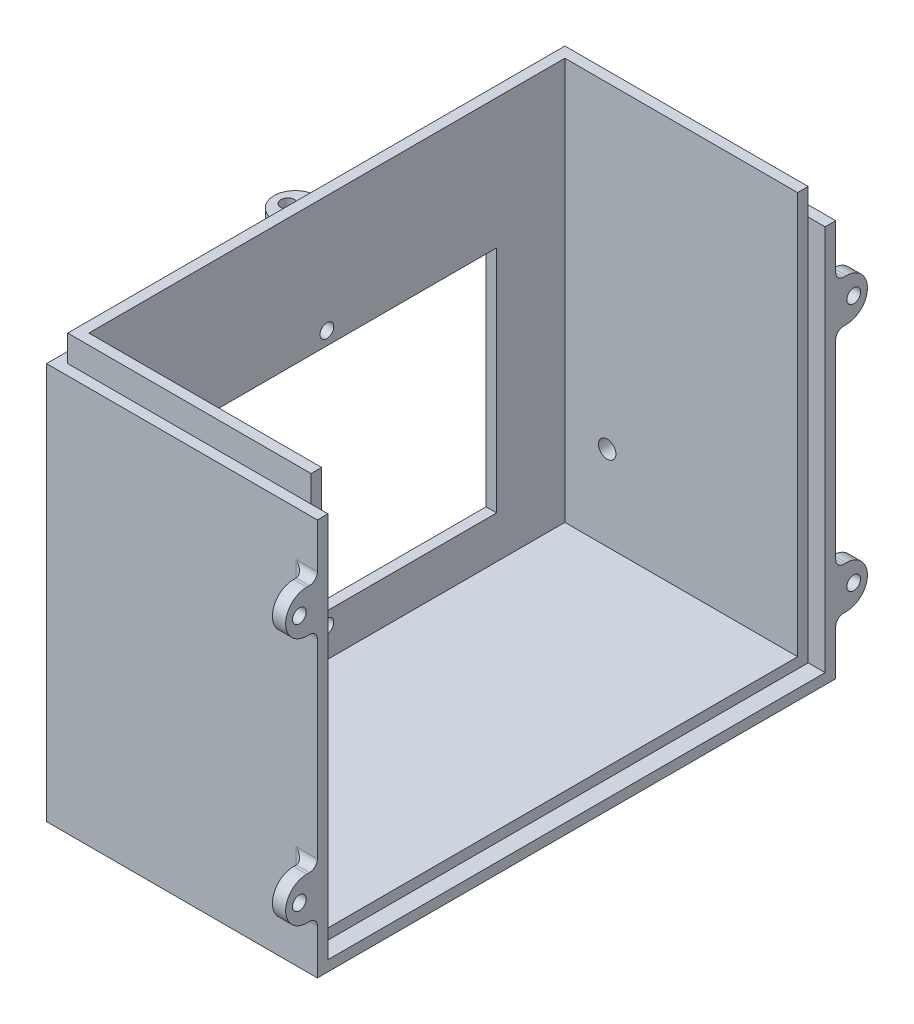
from build123d import *

# Parameters (mm, degrees)
SKETCH1_W           = 53
SKETCH1_H           = 98
BOSS_EXTRUDE1_DEPTH = 80
SKETCH2_W           = 90
SKETCH2_H           = 76
CUT_EXTRUDE1_DEPTH  = 49
SKETCH3_W           = 51
SKETCH3_H           = 2
CUT_EXTRUDE2_DEPTH  = 5
SKETCH5_W           = 2
SKETCH5_H           = 76
CUT_EXTRUDE3_DEPTH  = 5
CUT_EXTRUDE4_DEPTH  = 1.8
SKETCH8_R           = 1.3
BOSS_EXTRUDE3_DEPTH = 2.5
FILLET2_R           = 1.5
SKETCH9_R           = 1.3
BOSS_EXTRUDE4_DEPTH = 2.5
FILLET4_R           = 1.5
CUT_EXTRUDE6_REACH  = 53.2
SKETCH14_W          = 64.2
SKETCH14_H          = 43.4
SKETCH15_W          = 74.2
SKETCH15_H          = 53.4
CUT_EXTRUDE7_DEPTH  = 2
CUT_EXTRUDE8_REACH  = 51.2
SKETCH16_R          = 1.3
CUT_EXTRUDE12_REACH = 106
SKETCH29_R          = 1.65


with BuildPart() as part:
    # Sketch1 → Boss-Extrude1 (new body)
    with BuildSketch(Plane(origin=(0, 0, 0), x_dir=(1, 0, 0), z_dir=(0, 1, 0))):
        Rectangle(SKETCH1_W, SKETCH1_H)
    extrude(amount=BOSS_EXTRUDE1_DEPTH)

    # Sketch2 → Cut-Extrude1 (cut)
    with BuildSketch(Plane(origin=(26.5, 0, 0), x_dir=(0, 0, -1), z_dir=(1, 0, 0))):
        with Locations((0, 42)):
            Rectangle(SKETCH2_W, SKETCH2_H)
    extrude(amount=-CUT_EXTRUDE1_DEPTH, mode=Mode.SUBTRACT)

    # Sketch3 → Cut-Extrude2 (cut)
    with BuildSketch(Plane(origin=(0, 80, 0), x_dir=(1, 0, 0), z_dir=(0, 1, 0))):
        Polygon((-26.5, -49), (26.5, -49), (26.5, -47), (-24.5, -47), (-26.5, -47), align=None)
        Polygon((-26.5, 49), (-26.5, -47), (-24.5, -47), (-24.5, 47), (-24.5, 49), align=None)
        with Locations((1, 48)):
            Rectangle(SKETCH3_W, SKETCH3_H)
    extrude(amount=-CUT_EXTRUDE2_DEPTH, mode=Mode.SUBTRACT)

    # Sketch5 → Cut-Extrude3 (cut)
    with BuildSketch(Plane(origin=(26.5, 0, 0), x_dir=(0, 0, -1), z_dir=(1, 0, 0))):
        with Locations((-46, 42)):
            Rectangle(SKETCH5_W, SKETCH5_H)
        Polygon((-45, 4), (-47, 4), (-47, 2), (47, 2), (47, 4), (45, 4), align=None)
        with Locations((46, 42)):
            Rectangle(SKETCH5_W, SKETCH5_H)
    extrude(amount=-CUT_EXTRUDE3_DEPTH, mode=Mode.SUBTRACT)

    # Sketch6 → Cut-Extrude4 (cut)
    with BuildSketch(Plane(origin=(26.5, 0, 0), x_dir=(0, 0, -1), z_dir=(1, 0, 0))):
        Polygon((47, 75), (47, 2), (-47, 2), (-47, 75), (-49, 75), (-49, 0), (49, 0), (49, 75), align=None)
    extrude(amount=-CUT_EXTRUDE4_DEPTH, mode=Mode.SUBTRACT)

    # Sketch8 → Boss-Extrude3 (add)
    with BuildSketch(Plane(origin=(24.7, 0, 0), x_dir=(0, 0, -1), z_dir=(1, 0, 0))):
        with BuildLine():
            Line((-49, 10), (-51, 10))
            ThreePointArc((-51, 10), (-55, 14), (-51, 18))
            Line((-51, 18), (-49, 18))
            Line((-49, 18), (-49, 10))
        make_face()
        with Locations((-52.4, 14)):
            Circle(SKETCH8_R, mode=Mode.SUBTRACT)
        with BuildLine():
            Line((-49, 65), (-49, 57))
            Line((-49, 57), (-51, 57))
            ThreePointArc((-51, 57), (-55, 61), (-51, 65))
            Line((-51, 65), (-49, 65))
        make_face()
        with Locations((-52.4, 61)):
            Circle(SKETCH8_R, mode=Mode.SUBTRACT)
        with BuildLine():
            Line((49, 10), (49, 18))
            Line((49, 18), (51, 18))
            ThreePointArc((51, 18), (55, 14), (51, 10))
            Line((51, 10), (49, 10))
        make_face()
        with Locations((52.4, 14)):
            Circle(SKETCH8_R, mode=Mode.SUBTRACT)
        with BuildLine():
            Line((49, 65), (51, 65))
            ThreePointArc((51, 65), (55, 61), (51, 57))
            Line((51, 57), (49, 57))
            Line((49, 57), (49, 65))
        make_face()
        with Locations((52.4, 61)):
            Circle(SKETCH8_R, mode=Mode.SUBTRACT)
    extrude(amount=-BOSS_EXTRUDE3_DEPTH)

    # Fillet2
    fillet2_edges = [part.edges().sort_by_distance(p)[0] for p in [
        (22.2, 14, 49),
        (23.45, 18, 49),
        (23.45, 10, 49),
        (22.2, 61, 49),
        (23.45, 65, 49),
        (23.45, 57, 49),
        (22.2, 14, -49),
        (23.45, 10, -49),
        (23.45, 18, -49),
        (22.2, 61, -49),
        (23.45, 57, -49),
        (23.45, 65, -49),
    ]]
    fillet(fillet2_edges, radius=FILLET2_R)

    # Sketch9 → Boss-Extrude4 (add)
    with BuildSketch(Plane(origin=(0, 75, 0), x_dir=(1, 0, 0), z_dir=(0, 1, 0))):
        with BuildLine():
            Line((-26.5, 4), (-28.5, 4))
            ThreePointArc((-28.5, 4), (-32.5, 0), (-28.5, -4))
            Line((-28.5, -4), (-26.5, -4))
            Line((-26.5, -4), (-26.5, 4))
        make_face()
        with Locations((-29.9, 0)):
            Circle(SKETCH9_R, mode=Mode.SUBTRACT)
    extrude(amount=-BOSS_EXTRUDE4_DEPTH)

    # Fillet4
    fillet4_edges = [part.edges().sort_by_distance(p)[0] for p in [
        (-26.5, 72.5, 0),
        (-26.5, 73.75, -4),
        (-26.5, 73.75, 4),
    ]]
    fillet(fillet4_edges, radius=FILLET4_R)

    # Sketch14 → Cut-Extrude6 (cut, up to next)
    with BuildSketch(Plane.ZY.offset(26.5), mode=Mode.PRIVATE) as cut_extrude6_sk1:
        with Locations((0, 33.7)):
            Rectangle(SKETCH14_W, SKETCH14_H)
    cut_extrude6_tool1 = extrude(cut_extrude6_sk1.sketch, amount=-CUT_EXTRUDE6_REACH, mode=Mode.PRIVATE) & part.part
    add(cut_extrude6_tool1.solids().sort_by_distance((-26.5, 33.7, 0))[0], mode=Mode.SUBTRACT)

    # Sketch15 → Cut-Extrude7 (cut)
    with BuildSketch(Plane.ZY.offset(26.5)):
        with Locations((0, 33.7)):
            Rectangle(SKETCH15_W, SKETCH15_H)
    extrude(amount=-CUT_EXTRUDE7_DEPTH, mode=Mode.SUBTRACT)

    # Sketch16 → Cut-Extrude8 (cut, up to next)
    with BuildSketch(Plane.ZY.offset(24.5), mode=Mode.PRIVATE) as cut_extrude8_sk1:
        with Locations((0, 57.9)):
            Circle(SKETCH16_R)
    cut_extrude8_tool1 = extrude(cut_extrude8_sk1.sketch, amount=-CUT_EXTRUDE8_REACH, mode=Mode.PRIVATE) & part.part
    add(cut_extrude8_tool1.solids().sort_by_distance((-24.5, 57.9, 0))[0], mode=Mode.SUBTRACT)
    # Sketch16 → Cut-Extrude8 (cut, up to next)
    with BuildSketch(Plane.ZY.offset(24.5), mode=Mode.PRIVATE) as cut_extrude8_sk2:
        with Locations((0, 9.5)):
            Circle(SKETCH16_R)
    cut_extrude8_tool2 = extrude(cut_extrude8_sk2.sketch, amount=-CUT_EXTRUDE8_REACH, mode=Mode.PRIVATE) & part.part
    add(cut_extrude8_tool2.solids().sort_by_distance((-24.5, 9.5, 0))[0], mode=Mode.SUBTRACT)

    # Sketch29 → Cut-Extrude12 (cut, up to next)
    with BuildSketch(Plane(origin=(0, 0, -49), x_dir=(-1, 0, 0), z_dir=(0, 0, -1)), mode=Mode.PRIVATE) as cut_extrude12_sk1:
        with Locations((14.5, 20)):
            Circle(SKETCH29_R)
    cut_extrude12_tool1 = extrude(cut_extrude12_sk1.sketch, amount=-CUT_EXTRUDE12_REACH, mode=Mode.PRIVATE) & part.part
    add(cut_extrude12_tool1.solids().sort_by_distance((-14.5, 20, -49))[0], mode=Mode.SUBTRACT)


solid = part.part
